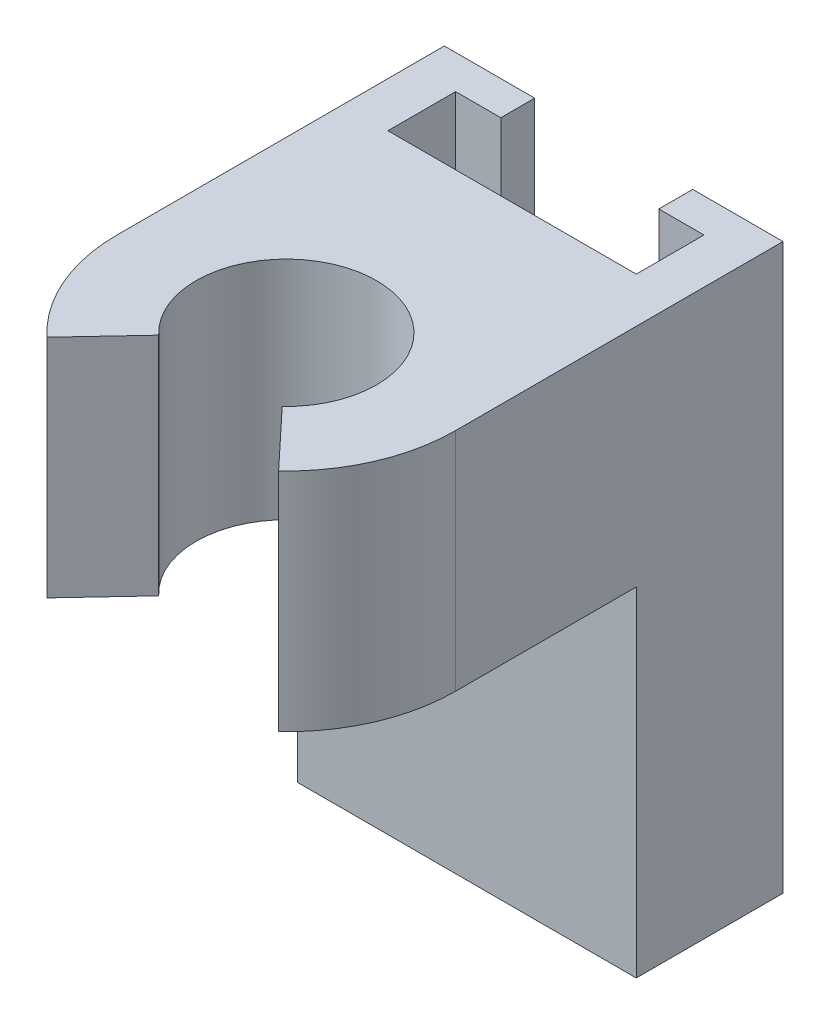
from build123d import *

# Parameters (mm, degrees)
BOSS_EXTRUDE2_DEPTH = 25
BOSS_EXTRUDE3_DEPTH = 10


with BuildPart() as part:
    # Sketch1 → Boss-Extrude2 (new body)
    with BuildSketch(Plane(origin=(0, 0, 0), x_dir=(1, 0, 0), z_dir=(0, 1, 0))):
        Polygon((0, 0), (15, 0), (15, 6.5), (11, 6.5), (11, 5), (13, 5), (13, 2), (2, 2), (2, 5), (4, 5), (4, 6.5), (0, 6.5), align=None)
    extrude(amount=BOSS_EXTRUDE2_DEPTH)

    # Sketch2 → Boss-Extrude3 (add)
    with BuildSketch(Plane(origin=(0, 25, 0), x_dir=(1, 0, 0), z_dir=(0, 1, 0))):
        with BuildLine():
            Line((15, -8), (15, 0))
            Line((15, 0), (0, 0))
            Line((0, 0), (0, -8))
            ThreePointArc((0, -8), (0.618078448, -10.981468724), (2.370441533, -13.471529031))
            Line((2.370441533, -13.471529031), (4.764235484, -10.918148817))
            ThreePointArc((4.764235484, -10.918148817), (7.5, -4), (10.235764516, -10.918148817))
            Line((10.235764516, -10.918148817), (12.629558467, -13.471529031))
            ThreePointArc((12.629558467, -13.471529031), (14.381921552, -10.981468724), (15, -8))
        make_face()
    extrude(amount=-BOSS_EXTRUDE3_DEPTH)


solid = part.part
